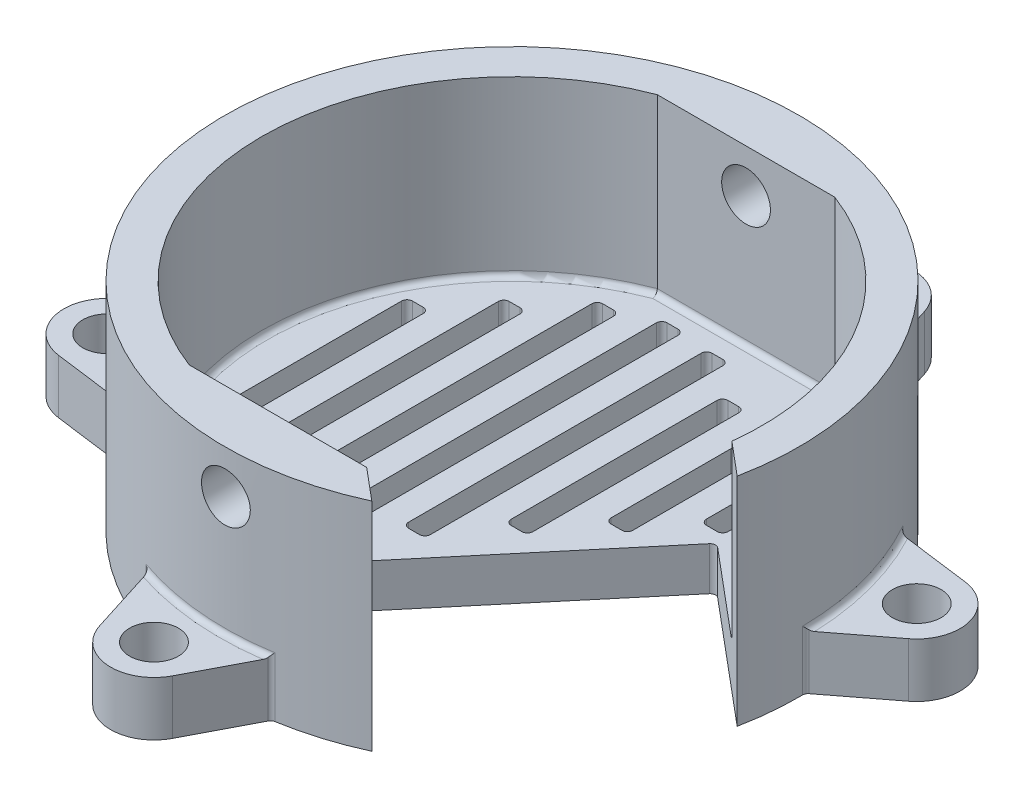
from build123d import *

# Parameters (mm, degrees)
BOSS_EXTRUDE1_DEPTH = 2
SKETCH2_R           = 13.25
BOSS_EXTRUDE2_DEPTH = 10
CUT_EXTRUDE1_DEPTH  = 8
CUT_EXTRUDE3_DEPTH  = 2
SKETCH4_R           = 1.125
CUT_EXTRUDE4_DEPTH  = 15
SKETCH5_R           = 1.125
BOSS_EXTRUDE4_DEPTH = 2.5
FILLET2_R           = 0.25
SKETCH6_W           = 1
SKETCH6_H           = 9
SKETCH6_H_2         = 14
SKETCH6_H_3         = 18
SKETCH6_H_4         = 19
SKETCH6_H_5         = 10
SKETCH6_H_6         = 6
SKETCH6_H_7         = 3
CUT_EXTRUDE5_DEPTH  = 2
FILLET3_R           = 0.25


with BuildPart() as part:
    # Sketch1 → Boss-Extrude1 (new body)
    with BuildSketch(Plane(origin=(0, 0, 0), x_dir=(1, 0, 0), z_dir=(0, 1, 0))):
        with BuildLine():
            Line((-4.094203219, 10.8), (4.094203219, 10.8))
            ThreePointArc((4.094203219, 10.8), (11.55, 0), (4.094203219, -10.8))
            Line((4.094203219, -10.8), (-4.094203219, -10.8))
            ThreePointArc((-4.094203219, -10.8), (-11.55, 0), (-4.094203219, 10.8))
        make_face()
    extrude(amount=BOSS_EXTRUDE1_DEPTH)

    # Sketch2 → Boss-Extrude2 (add)
    with BuildSketch(Plane(origin=(0, 0, 0), x_dir=(1, 0, 0), z_dir=(0, 1, 0))):
        Circle(SKETCH2_R)
        with BuildLine():
            Line((-4.094203219, -10.8), (4.094203219, -10.8))
            ThreePointArc((4.094203219, -10.8), (11.55, 0), (4.094203219, 10.8))
            Line((4.094203219, 10.8), (-4.094203219, 10.8))
            ThreePointArc((-4.094203219, 10.8), (-11.55, 0), (-4.094203219, -10.8))
        make_face(mode=Mode.SUBTRACT)
    extrude(amount=BOSS_EXTRUDE2_DEPTH)

    # Sketch3 → Cut-Extrude1 (cut)
    with BuildSketch(Plane(origin=(0, 2, 0), x_dir=(1, 0, 0), z_dir=(0, 1, 0))):
        with BuildLine():
            Line((4.094203219, -10.8), (-0.50206344, -6.943274342))
            Line((-0.50206344, -6.943274342), (7.211387877, 2.249258976))
            Line((7.211387877, 2.249258976), (11.473506452, -1.327083149))
            Line((11.473506452, -1.327083149), (12.992129547, -2.601359228))
            ThreePointArc((12.992129547, -2.601359228), (10.403847321, -8.205026564), (5.557738817, -12.02805218))
            Line((5.557738817, -12.02805218), (4.094203219, -10.8))
        make_face()
    extrude(amount=CUT_EXTRUDE1_DEPTH, mode=Mode.SUBTRACT)

    # Sketch3_3 → Cut-Extrude3 (cut)
    with BuildSketch(Plane(origin=(0, 2, 0), x_dir=(1, 0, 0), z_dir=(0, 1, 0))):
        with BuildLine():
            Line((4.094203219, -10.8), (-0.50206344, -6.943274342))
            Line((-0.50206344, -6.943274342), (7.211387877, 2.249258976))
            Line((7.211387877, 2.249258976), (11.473506452, -1.327083149))
            Line((11.473506452, -1.327083149), (12.992129547, -2.601359228))
            ThreePointArc((12.992129547, -2.601359228), (10.403847321, -8.205026564), (5.557738817, -12.02805218))
            Line((5.557738817, -12.02805218), (4.094203219, -10.8))
        make_face()
    extrude(amount=-CUT_EXTRUDE3_DEPTH, mode=Mode.SUBTRACT)

    # Sketch4 → Cut-Extrude4 (cut, symmetric)
    with BuildSketch(Plane.XY):
        with Locations((0, 8)):
            Circle(SKETCH4_R)
    extrude(amount=CUT_EXTRUDE4_DEPTH, both=True, mode=Mode.SUBTRACT)

    # Sketch5 → Boss-Extrude4 (add)
    with BuildSketch(Plane.XZ):
        with BuildLine():
            Line((3.236558978, -15.793380745), (4.260328754, -12.546397846))
            ThreePointArc((4.260328754, -12.546397846), (1.154813591, -13.19957975), (-2.016945665, -13.095588195))
            Line((-2.016945665, -13.095588195), (-0.444896589, -16.115466372))
            ThreePointArc((-0.444896589, -16.115466372), (1.503436562, -17.184358542), (3.236558978, -15.793380745))
        make_face()
        with Locations((1.329125077, -15.191969146)):
            Circle(SKETCH5_R, mode=Mode.SUBTRACT)
        with BuildLine():
            Line((15.947891709, -2.360283757), (13.246875724, -0.287721297))
            ThreePointArc((13.246875724, -0.287721297), (12.798517198, -3.429352348), (11.615991547, -6.37426391))
            Line((11.615991547, -6.37426391), (14.991421235, -5.929880161))
            ThreePointArc((14.991421235, -5.929880161), (16.662220503, -4.464628528), (15.947891709, -2.360283757))
        make_face()
        with Locations((14.730368851, -3.946990438)):
            Circle(SKETCH5_R, mode=Mode.SUBTRACT)
        with BuildLine():
            Line((-3.236558978, 15.793380745), (-4.260328754, 12.546397846))
            ThreePointArc((-4.260328754, 12.546397846), (-1.154813591, 13.19957975), (2.016945665, 13.095588195))
            Line((2.016945665, 13.095588195), (0.444896589, 16.115466372))
            ThreePointArc((0.444896589, 16.115466372), (-1.503436562, 17.184358542), (-3.236558978, 15.793380745))
        make_face()
        with Locations((-1.329125077, 15.191969146)):
            Circle(SKETCH5_R, mode=Mode.SUBTRACT)
        with BuildLine():
            Line((-15.947891709, 2.360283757), (-13.246875724, 0.287721297))
            ThreePointArc((-13.246875724, 0.287721297), (-12.798517198, 3.429352348), (-11.615991547, 6.37426391))
            Line((-11.615991547, 6.37426391), (-14.991421235, 5.929880161))
            ThreePointArc((-14.991421235, 5.929880161), (-16.662220503, 4.464628528), (-15.947891709, 2.360283757))
        make_face()
        with Locations((-14.730368851, 3.946990438)):
            Circle(SKETCH5_R, mode=Mode.SUBTRACT)
    extrude(amount=-BOSS_EXTRUDE4_DEPTH)

    # Fillet2
    fillet2_edges = [part.edges().sort_by_distance(p)[0] for p in [
        (-1.154813591, 2.5, 13.19957975),
        (2.016945665, 1.25, 13.095588195),
        (-4.260328754, 1.25, 12.546397846),
        (-12.798517198, 2.5, 3.429352348),
        (-11.615991547, 1.25, 6.37426391),
        (-13.246875724, 1.25, 0.287721297),
        (0, 2, -10.8),
        (9.866860318, 2, -6.003962647),
        (-11.55, 2, 0),
        (-0.50206344, 1, 6.943274342),
        (7.211387877, 1, -2.249258976),
        (1.154813591, 2.5, -13.19957975),
        (-2.016945665, 1.25, -13.095588195),
        (4.260328754, 1.25, -12.546397846),
        (0, 2, 10.8),
        (12.798517198, 2.5, -3.429352348),
        (11.615991547, 1.25, -6.37426391),
        (13.246875724, 1.25, -0.287721297),
    ]]
    fillet(fillet2_edges, radius=FILLET2_R)

    # Sketch6 → Cut-Extrude5 (cut)
    with BuildSketch(Plane.XZ):
        with Locations((-9.25, -0.40318756)):
            Rectangle(SKETCH6_W, SKETCH6_H)
        with Locations((-7, -0.119489057)):
            Rectangle(SKETCH6_W, SKETCH6_H_2)
        with Locations((-4.75, -0.183989082)):
            Rectangle(SKETCH6_W, SKETCH6_H_3)
        with Locations((-2.5, -0.407091801)):
            Rectangle(SKETCH6_W, SKETCH6_H_4)
        with Locations((-0.25, -2.730474383)):
            Rectangle(SKETCH6_W, SKETCH6_H_2)
        with Locations((2, -3.212459658)):
            Rectangle(SKETCH6_W, SKETCH6_H_5)
        with Locations((4.25, -3.573003756)):
            Rectangle(SKETCH6_W, SKETCH6_H_6)
        with Locations((6.5, -4.222915511)):
            Rectangle(SKETCH6_W, SKETCH6_H_7)
    extrude(amount=-CUT_EXTRUDE5_DEPTH, mode=Mode.SUBTRACT)

    # Fillet3
    fillet3_edges = [part.edges().sort_by_distance(p)[0] for p in [
        (-8.75, 1, -4.90318756),
        (-8.75, 1, 4.09681244),
        (-9.75, 1, 4.09681244),
        (-9.75, 1, -4.90318756),
        (-6.5, 1, -7.119489057),
        (-6.5, 1, 6.880510943),
        (-7.5, 1, 6.880510943),
        (-7.5, 1, -7.119489057),
        (-4.25, 1, -9.183989082),
        (-4.25, 1, 8.816010918),
        (-5.25, 1, 8.816010918),
        (-5.25, 1, -9.183989082),
        (-2, 1, -9.907091801),
        (-2, 1, 9.092908199),
        (-3, 1, 9.092908199),
        (-3, 1, -9.907091801),
        (0.25, 1, -9.730474383),
        (0.25, 1, 4.269525617),
        (-0.75, 1, 4.269525617),
        (-0.75, 1, -9.730474383),
        (2.5, 1, -8.212459658),
        (2.5, 1, 1.787540342),
        (1.5, 1, 1.787540342),
        (1.5, 1, -8.212459658),
        (4.75, 1, -6.573003756),
        (4.75, 1, -0.573003756),
        (3.75, 1, -0.573003756),
        (3.75, 1, -6.573003756),
        (7, 1, -5.722915511),
        (7, 1, -2.722915511),
        (6, 1, -2.722915511),
        (6, 1, -5.722915511),
    ]]
    fillet(fillet3_edges, radius=FILLET3_R)


solid = part.part
